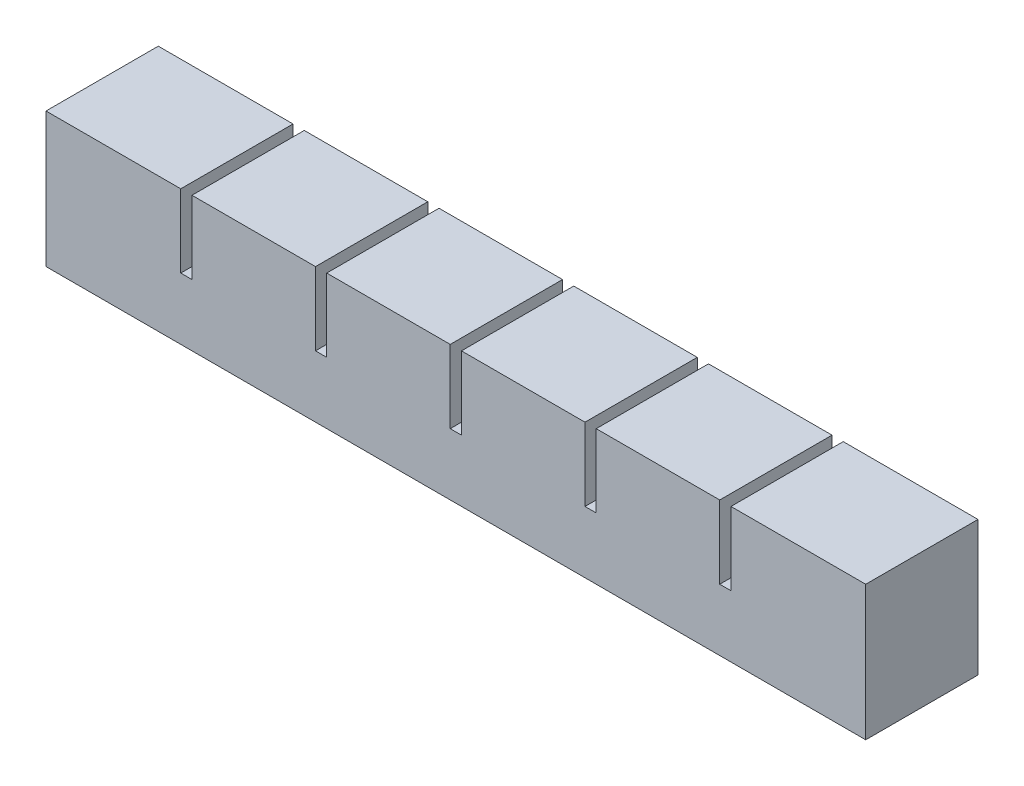
from build123d import *

# Parameters (mm, degrees)
SKETCH1_W           = 22
SKETCH1_H           = 18
BOSS_EXTRUDE1_DEPTH = 20
SKETCH2_W           = 12
SKETCH2_H           = 10
CUT_EXTRUDE1_DEPTH  = 13
SKETCH3_W           = 20
SKETCH3_H           = 5
BOSS_EXTRUDE2_DEPTH = 2
LPATTERN1_COUNT     = 6
LPATTERN1_PITCH     = 24
SKETCH4_W           = 20
SKETCH4_H           = 13
BOSS_EXTRUDE3_DEPTH = 2
SKETCH5_W           = 20
SKETCH5_H           = 18
BOSS_EXTRUDE4_DEPTH = 2
SKETCH6_W           = 132
SKETCH6_H           = 2
CUT_EXTRUDE2_DEPTH  = 2
SKETCH7_W           = 146
SKETCH7_H           = 20
BOSS_EXTRUDE5_DEPTH = 6


with BuildPart() as part:
    # Sketch1 → Boss-Extrude1 (new body)
    with BuildSketch(Plane.XY):
        with Locations((11, 9)):
            Rectangle(SKETCH1_W, SKETCH1_H)
    extrude(amount=BOSS_EXTRUDE1_DEPTH)

    # Sketch2 → Cut-Extrude1 (cut)
    with BuildSketch(Plane.XZ):
        with Locations((11, 10)):
            Rectangle(SKETCH2_W, SKETCH2_H)
    extrude(amount=-CUT_EXTRUDE1_DEPTH, mode=Mode.SUBTRACT)

    # Sketch3 → Boss-Extrude2 (add)
    with BuildSketch(Plane(origin=(22, 0, 0), x_dir=(0, 0, -1), z_dir=(1, 0, 0))):
        with Locations((-10, 2.5)):
            Rectangle(SKETCH3_W, SKETCH3_H)
    extrude(amount=BOSS_EXTRUDE2_DEPTH)


with BuildPart() as lpattern1_1:
    # LPattern1: pattern copy
    add(part.part.moved(Location(Vector(1, 0, 0) * (1 * LPATTERN1_PITCH))))


with BuildPart() as lpattern1_2:
    # LPattern1: pattern copy
    add(part.part.moved(Location(Vector(1, 0, 0) * (2 * LPATTERN1_PITCH))))


with BuildPart() as lpattern1_3:
    # LPattern1: pattern copy
    add(part.part.moved(Location(Vector(1, 0, 0) * (3 * LPATTERN1_PITCH))))


with BuildPart() as lpattern1_4:
    # LPattern1: pattern copy
    add(part.part.moved(Location(Vector(1, 0, 0) * (4 * LPATTERN1_PITCH))))


with BuildPart() as lpattern1_5:
    # LPattern1: pattern copy
    add(part.part.moved(Location(Vector(1, 0, 0) * (5 * LPATTERN1_PITCH))))

    # Sketch4 → Boss-Extrude3 (add)
    with BuildSketch(Plane(origin=(142, 0, 0), x_dir=(0, 0, -1), z_dir=(1, 0, 0))):
        with Locations((-10, 11.5)):
            Rectangle(SKETCH4_W, SKETCH4_H)
    extrude(amount=BOSS_EXTRUDE3_DEPTH)


with BuildPart() as part_1:
    add(part.part)

    # Sketch5 → Boss-Extrude4 (add)
    with BuildSketch(Plane.ZY):
        with Locations((10, 9)):
            Rectangle(SKETCH5_W, SKETCH5_H)
    extrude(amount=BOSS_EXTRUDE4_DEPTH)


with BuildPart() as lpattern1_1_1:
    add(lpattern1_1.part)

    # Combine1: union LPattern1_2, LPattern1_3, LPattern1_4, LPattern1_5, part
    add(lpattern1_2.part)
    add(lpattern1_3.part)
    add(lpattern1_4.part)
    add(lpattern1_5.part)
    add(part_1.part)

    # Sketch6 → Cut-Extrude2 (cut)
    with BuildSketch(Plane(origin=(0, 0, 0), x_dir=(-1, 0, 0), z_dir=(0, -1, 0))):
        with Locations((-71, -10)):
            Rectangle(SKETCH6_W, SKETCH6_H)
    extrude(amount=-CUT_EXTRUDE2_DEPTH, mode=Mode.SUBTRACT)

    # Sketch7 → Boss-Extrude5 (add)
    with BuildSketch(Plane(origin=(0, 0, 0), x_dir=(-1, 0, 0), z_dir=(0, -1, 0))):
        with Locations((-71, -10)):
            Rectangle(SKETCH7_W, SKETCH7_H)
    extrude(amount=BOSS_EXTRUDE5_DEPTH)


solid = lpattern1_1_1.part
